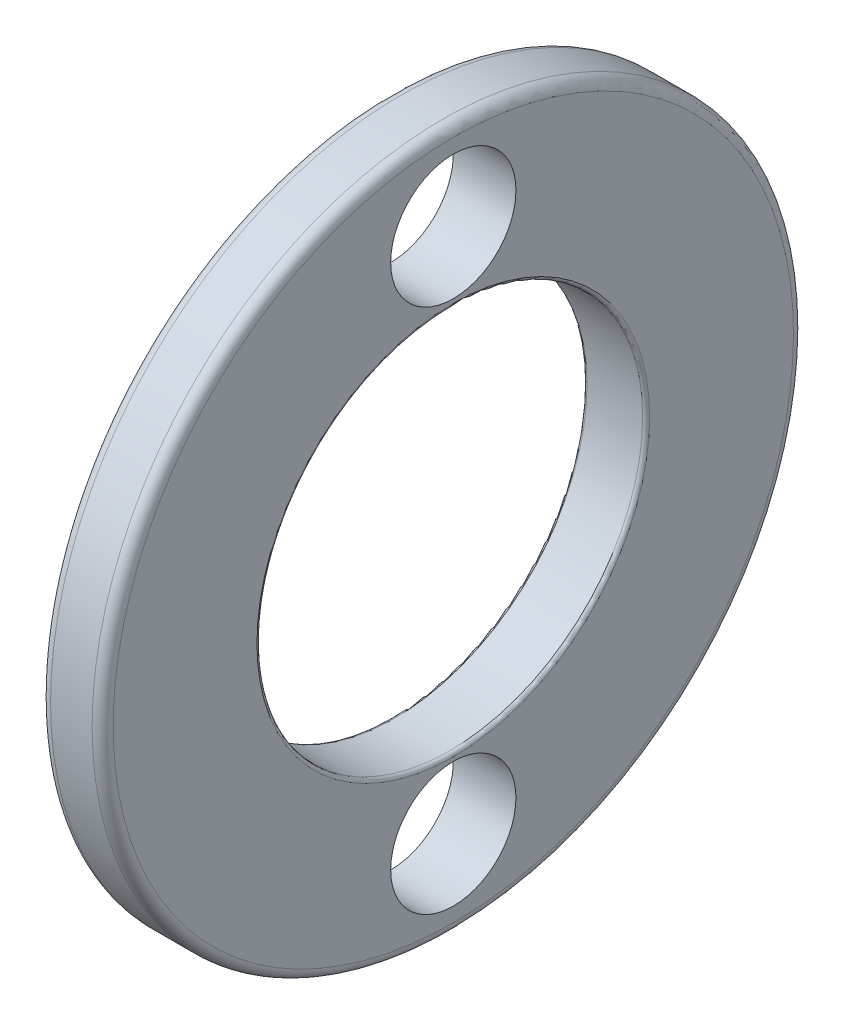
from build123d import *

# Parameters (mm, degrees)
CROQUIS2_R     = 3.572
EXTRUIR1_DEPTH = 12.358
CROQUIS3_R     = 3.572
EXTRUIR2_DEPTH = 12.358


with BuildPart() as part:
    # Croquis1 → Revolución1 (revolve)
    with BuildSketch(Plane.XY):
        with BuildLine():
            Line((5.214, 19.4), (5.214, 11.2))
            ThreePointArc((5.214, 11.2), (5.272578644, 11.058578644), (5.414, 11))
            Line((5.414, 11), (8.586, 11))
            ThreePointArc((8.586, 11), (8.727421356, 11.058578644), (8.786, 11.2))
            Line((8.786, 11.2), (8.786, 19.4))
            ThreePointArc((8.786, 19.4), (8.610264069, 19.824264069), (8.186, 20))
            Line((8.186, 20), (5.814, 20))
            ThreePointArc((5.814, 20), (5.389735931, 19.824264069), (5.214, 19.4))
        make_face()
    revolve(axis=Axis((50, 0, 0), (-1, 0, 0)))

    # Croquis2 → Extruir1 (cut)
    with BuildSketch(Plane(origin=(0, 0, 0), x_dir=(0, 0, -1), z_dir=(1, 0, 0))):
        with Locations((0, 15)):
            Circle(CROQUIS2_R)
    extrude(amount=EXTRUIR1_DEPTH, mode=Mode.SUBTRACT)

    # Croquis3 → Extruir2 (cut)
    with BuildSketch(Plane(origin=(0, 0, 0), x_dir=(0, 0, -1), z_dir=(1, 0, 0))):
        with Locations((0, -15)):
            Circle(CROQUIS3_R)
    extrude(amount=EXTRUIR2_DEPTH, mode=Mode.SUBTRACT)


solid = part.part
